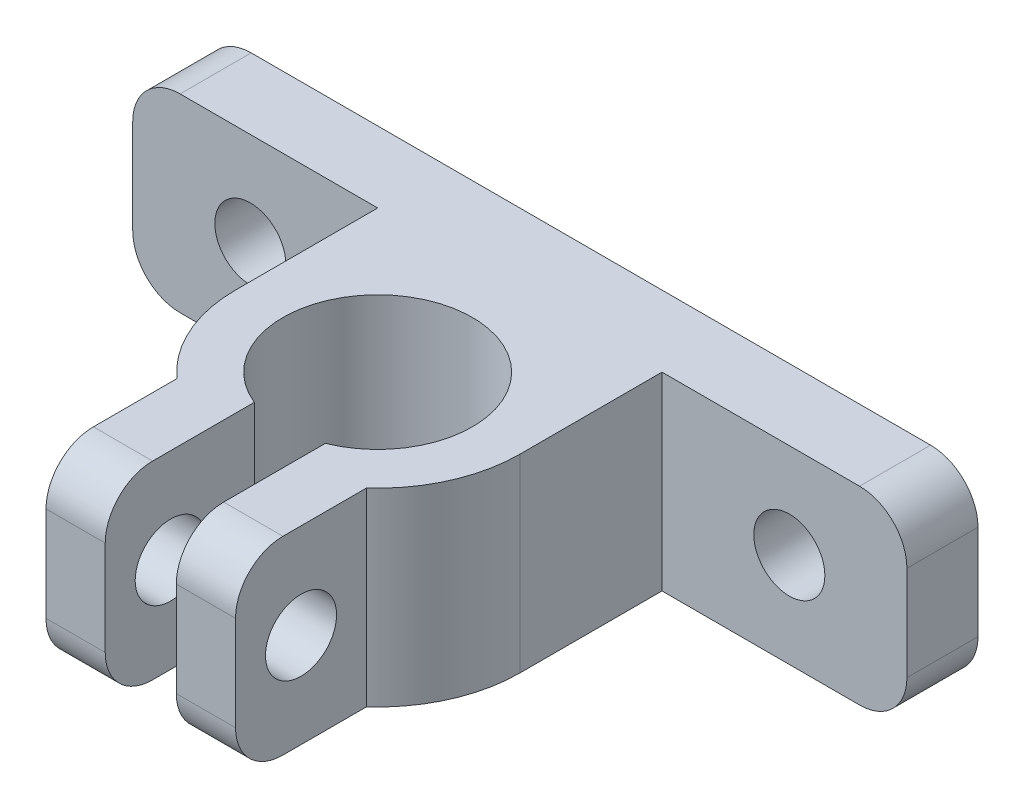
from build123d import *

# Parameters (mm, degrees)
SKETCH_1_W          = 32.677388302
SKETCH_1_H          = 8
EXTRUDE_1_DEPTH     = 3
SKETCH_2_R          = 1.5
CUT_EXTRUDE_1_DEPTH = 4
SKETCH_3_R          = 6
EXTRUDE_2_DEPTH     = 8
SKETCH_4_R          = 4
CUT_EXTRUDE_2_DEPTH = 9
EXTRUDE_3_DEPTH     = 8
SKETCH_6_W          = 8
SKETCH_6_H          = 6
EXTRUDE_4_DEPTH     = 8
SKETCH_8_W          = 3
SKETCH_8_H          = 10.466633743
CUT_EXTRUDE_5_DEPTH = 9
SKETCH_9_R          = 1.5
CUT_EXTRUDE_6_DEPTH = 21.338694151
FILLET_1_R          = 2
FILLET_2_R          = 2


with BuildPart() as part:
    # 草图1 → 凸台-拉伸1 (new body)
    with BuildSketch(Plane.XY):
        with Locations((-3.726697353, 26.358574689)):
            Rectangle(SKETCH_1_W, SKETCH_1_H)
    extrude(amount=-EXTRUDE_1_DEPTH)

    # 草图2 → 切除-拉伸1 (cut, through all)
    with BuildSketch(Plane.XY):
        with Locations((-15.101697353, 26.358574689)):
            Circle(SKETCH_2_R)
        with Locations((7.648302647, 26.358574689)):
            Circle(SKETCH_2_R)
    extrude(amount=-CUT_EXTRUDE_1_DEPTH, mode=Mode.SUBTRACT)



with BuildPart() as body_2:
    # 草图3 → 凸台-拉伸2 (new body)
    with BuildSketch(Plane.XZ.offset(-22.358574689)):
        with Locations((-3.726697353, 6)):
            Circle(SKETCH_3_R)
    extrude(amount=-EXTRUDE_2_DEPTH)

    # 草图4 → 切除-拉伸2 (cut, through all)
    with BuildSketch(Plane.XZ.offset(-22.358574689)):
        with Locations((-3.726697353, 6)):
            Circle(SKETCH_4_R)
    extrude(amount=-CUT_EXTRUDE_2_DEPTH, mode=Mode.SUBTRACT)


with BuildPart() as part_1:
    add(part.part)

    add(body_2.part)  # 凸台-拉伸3 merges body 2
    # 草图5 → 凸台-拉伸3 (add)
    with BuildSketch(Plane.XZ.offset(-22.358574689)):
        Polygon((-3.726697353, 0), (-9.726697353, 6), (-9.726697353, 0), align=None)
        Polygon((2.273302647, 6), (-3.726697353, 0), (2.273302647, 0), align=None)
    extrude(amount=-EXTRUDE_3_DEPTH)

    # 草图6 → 凸台-拉伸4 (add)
    with BuildSketch(Plane.XZ.offset(-22.358574689)):
        with Locations((-3.726697353, 13)):
            Rectangle(SKETCH_6_W, SKETCH_6_H)
    extrude(amount=-EXTRUDE_4_DEPTH)

    # 草图8 → 切除-拉伸5 (cut, through all)
    with BuildSketch(Plane.XZ.offset(-22.358574689)):
        with Locations((-3.726697353, 11.233316872)):
            Rectangle(SKETCH_8_W, SKETCH_8_H)
    extrude(amount=-CUT_EXTRUDE_5_DEPTH, mode=Mode.SUBTRACT)

    # 草图9 → 切除-拉伸6 (cut, through all)
    with BuildSketch(Plane(origin=(0.273302647, 0, 0), x_dir=(0, 0, -1), z_dir=(1, 0, 0))):
        with Locations((-13.236067977, 26.358574689)):
            Circle(SKETCH_9_R)
    extrude(amount=-CUT_EXTRUDE_6_DEPTH, mode=Mode.SUBTRACT)

    # 圆角1
    fillet_1_edges = [part_1.edges().sort_by_distance(p)[0] for p in [
        (12.611996798, 22.358574689, -1.5),
        (-20.065391504, 22.358574689, -1.5),
        (-20.065391504, 30.358574689, -1.5),
        (12.611996798, 30.358574689, -1.5),
    ]]
    fillet(fillet_1_edges, radius=FILLET_1_R)

    # 圆角2
    fillet_2_edges = [part_1.edges().sort_by_distance(p)[0] for p in [
        (-0.976697353, 22.358574689, 16),
        (-0.976697353, 30.358574689, 16),
        (-6.476697353, 30.358574689, 16),
        (-6.476697353, 22.358574689, 16),
    ]]
    fillet(fillet_2_edges, radius=FILLET_2_R)


solid = part_1.part
